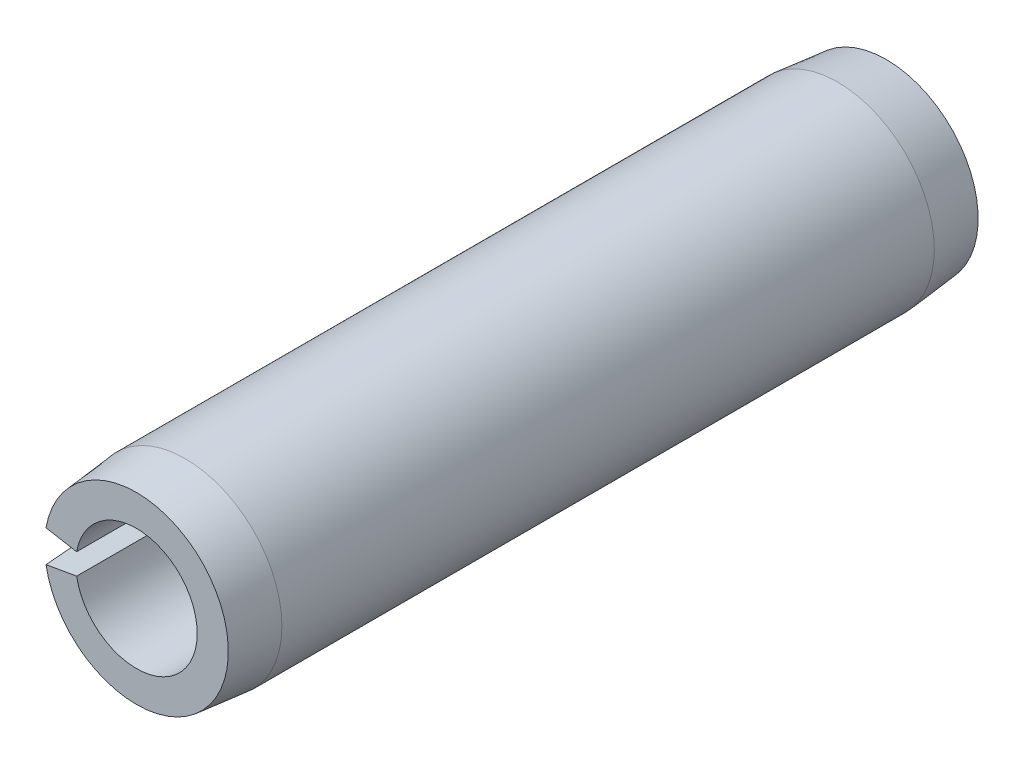
from build123d import *

# Parameters (mm, degrees)
EXTRUDE1_DEPTH = 12.7


with BuildPart() as part:
    # Sketch1 → Extrude1 (new body, symmetric)
    with BuildSketch(Plane.XY):
        with BuildLine():
            Line((-3.226821084, 0.568975619), (-2.026143471, 0.357263761))
            ThreePointArc((-2.026143471, 0.357263761), (2.0574, 0), (-2.026143471, -0.357263761))
            Line((-2.026143471, -0.357263761), (-3.226821084, -0.568975619))
            ThreePointArc((-3.226821084, -0.568975619), (3.2766, 0), (-3.226821084, 0.568975619))
        make_face()
    extrude(amount=EXTRUDE1_DEPTH, both=True)

    # Sketch2 → Cut-Revolve1 (revolve, cut)
    with BuildSketch(Plane(origin=(0, 0, 0), x_dir=(0, 0, -1), z_dir=(1, 0, 0))):
        Polygon((12.7, 3.2766), (12.7, 3.1115), (11.049, 3.2766), align=None)
        Polygon((-11.049, 3.2766), (-12.7, 3.2766), (-12.7, 3.1115), align=None)
    revolve(axis=Axis((0, 0, -12.7), (0, 0, 1)), mode=Mode.SUBTRACT)


solid = part.part
